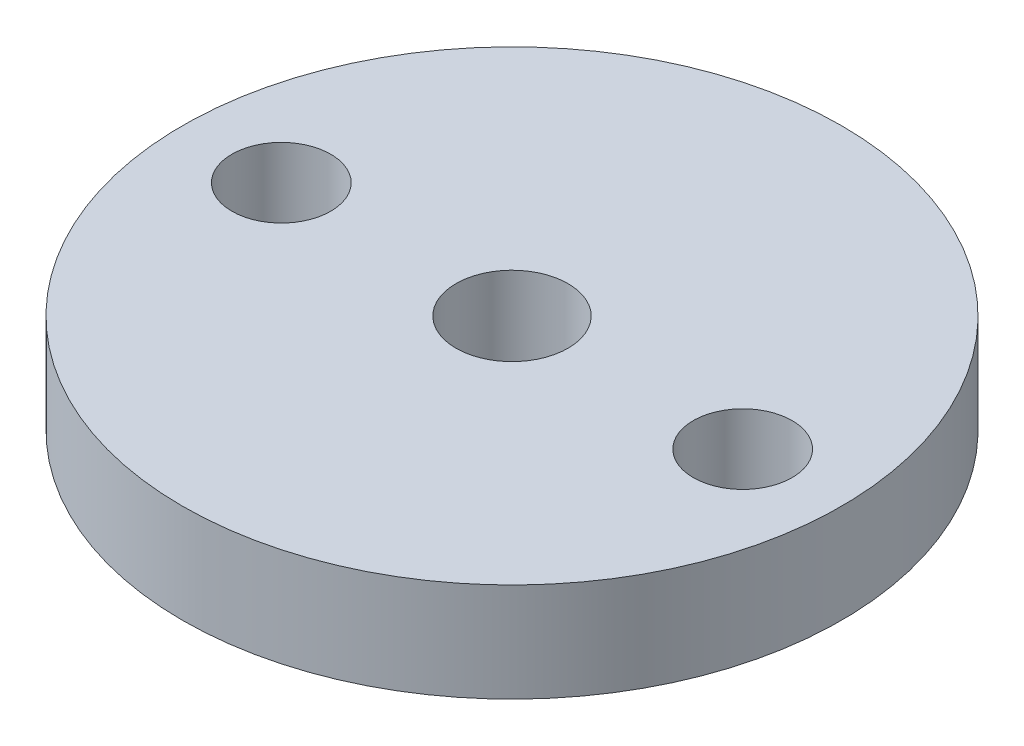
from build123d import *

# Parameters (mm, degrees)
CROQUIS1_R              = 10
CROQUIS1_R_2            = 1.7
CROQUIS1_R_3            = 1.5
SALIENTE_EXTRUIR1_DEPTH = 3


with BuildPart() as part:
    # Croquis1 → Saliente-Extruir1 (new body)
    with BuildSketch(Plane(origin=(0, 0, 0), x_dir=(1, 0, 0), z_dir=(0, 1, 0))):
        Circle(CROQUIS1_R)
        Circle(CROQUIS1_R_2, mode=Mode.SUBTRACT)
        with Locations((7, 0)):
            Circle(CROQUIS1_R_3, mode=Mode.SUBTRACT)
        with Locations((-7, 0)):
            Circle(CROQUIS1_R_3, mode=Mode.SUBTRACT)
    extrude(amount=SALIENTE_EXTRUIR1_DEPTH)


solid = part.part
